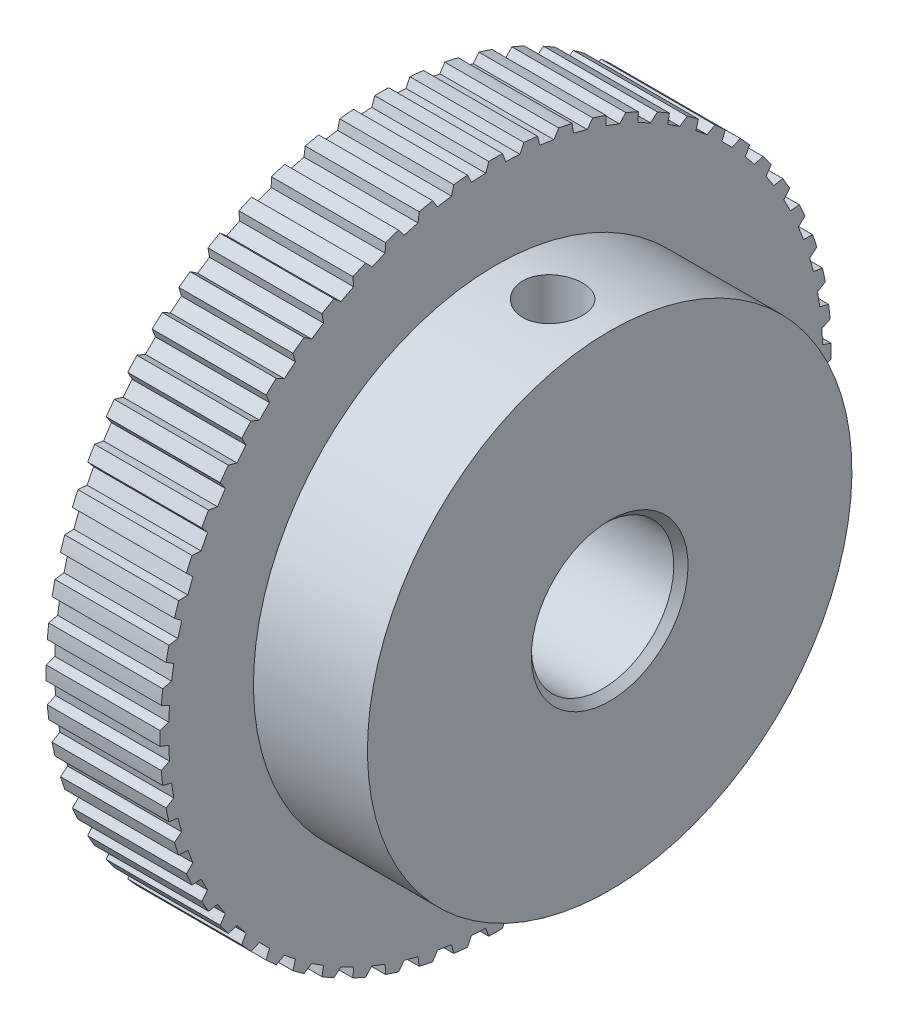
from build123d import *

# Parameters (mm, degrees)
ENL_V_MAT_EXTRU_2_DEPTH = 17
ESQUISSE3_R             = 5
ENL_V_MAT_EXTRU_3_DEPTH = 17
CHANFREIN1_SIZE         = 0.5
ESQUISSE4_W             = 2.1
ESQUISSE4_H             = 23.55


with BuildPart() as part:
    # Esquisse1 → Révolution1 (revolve)
    with BuildSketch(Plane.XY):
        Polygon((0, 0), (0, 21.05), (0, 23.55), (8, 23.55), (8, 21.05), (8, 17), (16, 17), (16, 0), align=None)
    revolve(axis=Axis((16, 0, 0), (-1, 0, 0)))

    # Esquisse2 → Enlèv. mat.-Extru.2 (cut, through all)
    with BuildSketch(Plane.ZY):
        Polygon((0.701110196, 22.944751712), (0.418973605, 23.719915625), (2.062727906, 23.633770113), (1.701110196, 22.892343933), align=None)
        Polygon((3.095649077, 22.74577199), (2.896084753, 23.546180779), (4.521829737, 23.288688069), (4.084692868, 22.589122843), align=None)
        Polygon((5.45627138, 22.297584831), (5.34146579, 23.114469048), (6.931389456, 22.688450285), (6.42352279, 22.038410596), align=None)
        Polygon((7.757113631, 21.605100665), (7.72832461, 22.429510357), (9.265007422, 21.839633093), (8.691975253, 21.246240911), align=None)
        Polygon((9.972967322, 20.675906496), (10.030510289, 21.498809258), (11.497116027, 20.751536309), (10.865196616, 20.221292964), align=None)
        Polygon((12.079555097, 19.520182768), (12.222799598, 20.332562705), (13.603259824, 19.436081352), (12.919376611, 18.9747963), align=None)
        Polygon((14.053796737, 18.150591834), (14.281173357, 18.94354834), (15.560363459, 17.90768062), (14.832009212, 17.520407797), align=None)
        Polygon((15.87406204, 16.582139216), (16.183079591, 17.346984495), (17.346984495, 16.183079591), (16.582139216, 15.87406204), align=None)
        Polygon((17.520407797, 14.832009212), (17.90768062, 15.560363459), (18.94354834, 14.281173357), (18.150591834, 14.053796737), align=None)
        Polygon((18.9747963, 12.919376611), (19.436081352, 13.603259824), (20.332562705, 12.222799598), (19.520182768, 12.079555097), align=None)
        Polygon((20.221292964, 10.865196616), (20.751536309, 11.497116027), (21.498809258, 10.030510289), (20.675906496, 9.972967322), align=None)
        Polygon((21.246240911, 8.691975253), (21.839633093, 9.265007422), (22.429510357, 7.72832461), (21.605100665, 7.757113631), align=None)
        Polygon((22.038410596, 6.42352279), (22.688450285, 6.931389456), (23.114469048, 5.34146579), (22.297584831, 5.45627138), align=None)
        Polygon((22.589122843, 4.084692868), (23.288688069, 4.521829737), (23.546180779, 2.896084753), (22.74577199, 3.095649077), align=None)
        Polygon((22.892343933, 1.701110196), (23.633770113, 2.062727906), (23.719915625, 0.418973605), (22.944751712, 0.701110196), align=None)
        Polygon((22.944751712, -0.701110196), (23.719915625, -0.418973605), (23.633770113, -2.062727906), (22.892343933, -1.701110196), align=None)
        Polygon((22.74577199, -3.095649077), (23.546180779, -2.896084753), (23.288688069, -4.521829737), (22.589122843, -4.084692868), align=None)
        Polygon((22.297584831, -5.45627138), (23.114469048, -5.34146579), (22.688450285, -6.931389456), (22.038410596, -6.42352279), align=None)
        Polygon((21.605100665, -7.757113631), (22.429510357, -7.72832461), (21.839633093, -9.265007422), (21.246240911, -8.691975253), align=None)
        Polygon((20.675906496, -9.972967322), (21.498809258, -10.030510289), (20.751536309, -11.497116027), (20.221292964, -10.865196616), align=None)
        Polygon((19.520182768, -12.079555097), (20.332562705, -12.222799598), (19.436081352, -13.603259824), (18.9747963, -12.919376611), align=None)
        Polygon((18.150591834, -14.053796737), (18.94354834, -14.281173357), (17.90768062, -15.560363459), (17.520407797, -14.832009212), align=None)
        Polygon((16.582139216, -15.87406204), (17.346984495, -16.183079591), (16.183079591, -17.346984495), (15.87406204, -16.582139216), align=None)
        Polygon((14.832009212, -17.520407797), (15.560363459, -17.90768062), (14.281173357, -18.94354834), (14.053796737, -18.150591834), align=None)
        Polygon((12.919376611, -18.9747963), (13.603259824, -19.436081352), (12.222799598, -20.332562705), (12.079555097, -19.520182768), align=None)
        Polygon((10.865196616, -20.221292964), (11.497116027, -20.751536309), (10.030510289, -21.498809258), (9.972967322, -20.675906496), align=None)
        Polygon((8.691975253, -21.246240911), (9.265007422, -21.839633093), (7.72832461, -22.429510357), (7.757113631, -21.605100665), align=None)
        Polygon((6.42352279, -22.038410596), (6.931389456, -22.688450285), (5.34146579, -23.114469048), (5.45627138, -22.297584831), align=None)
        Polygon((4.084692868, -22.589122843), (4.521829737, -23.288688069), (2.896084753, -23.546180779), (3.095649077, -22.74577199), align=None)
        Polygon((1.701110196, -22.892343933), (2.062727906, -23.633770113), (0.418973605, -23.719915625), (0.701110196, -22.944751712), align=None)
        Polygon((-0.701110196, -22.944751712), (-0.418973605, -23.719915625), (-2.062727906, -23.633770113), (-1.701110196, -22.892343933), align=None)
        Polygon((-3.095649077, -22.74577199), (-2.896084753, -23.546180779), (-4.521829737, -23.288688069), (-4.084692868, -22.589122843), align=None)
        Polygon((-5.45627138, -22.297584831), (-5.34146579, -23.114469048), (-6.931389456, -22.688450285), (-6.42352279, -22.038410596), align=None)
        Polygon((-7.757113631, -21.605100665), (-7.72832461, -22.429510357), (-9.265007422, -21.839633093), (-8.691975253, -21.246240911), align=None)
        Polygon((-9.972967322, -20.675906496), (-10.030510289, -21.498809258), (-11.497116027, -20.751536309), (-10.865196616, -20.221292964), align=None)
        Polygon((-12.079555097, -19.520182768), (-12.222799598, -20.332562705), (-13.603259824, -19.436081352), (-12.919376611, -18.9747963), align=None)
        Polygon((-14.053796737, -18.150591834), (-14.281173357, -18.94354834), (-15.560363459, -17.90768062), (-14.832009212, -17.520407797), align=None)
        Polygon((-15.87406204, -16.582139216), (-16.183079591, -17.346984495), (-17.346984495, -16.183079591), (-16.582139216, -15.87406204), align=None)
        Polygon((-17.520407797, -14.832009212), (-17.90768062, -15.560363459), (-18.94354834, -14.281173357), (-18.150591834, -14.053796737), align=None)
        Polygon((-18.9747963, -12.919376611), (-19.436081352, -13.603259824), (-20.332562705, -12.222799598), (-19.520182768, -12.079555097), align=None)
        Polygon((-20.221292964, -10.865196616), (-20.751536309, -11.497116027), (-21.498809258, -10.030510289), (-20.675906496, -9.972967322), align=None)
        Polygon((-21.246240911, -8.691975253), (-21.839633093, -9.265007422), (-22.429510357, -7.72832461), (-21.605100665, -7.757113631), align=None)
        Polygon((-22.038410596, -6.42352279), (-22.688450285, -6.931389456), (-23.114469048, -5.34146579), (-22.297584831, -5.45627138), align=None)
        Polygon((-22.589122843, -4.084692868), (-23.288688069, -4.521829737), (-23.546180779, -2.896084753), (-22.74577199, -3.095649077), align=None)
        Polygon((-22.892343933, -1.701110196), (-23.633770113, -2.062727906), (-23.719915625, -0.418973605), (-22.944751712, -0.701110196), align=None)
        Polygon((-22.944751712, 0.701110196), (-23.719915625, 0.418973605), (-23.633770113, 2.062727906), (-22.892343933, 1.701110196), align=None)
        Polygon((-22.74577199, 3.095649077), (-23.546180779, 2.896084753), (-23.288688069, 4.521829737), (-22.589122843, 4.084692868), align=None)
        Polygon((-22.297584831, 5.45627138), (-23.114469048, 5.34146579), (-22.688450285, 6.931389456), (-22.038410596, 6.42352279), align=None)
        Polygon((-21.605100665, 7.757113631), (-22.429510357, 7.72832461), (-21.839633093, 9.265007422), (-21.246240911, 8.691975253), align=None)
        Polygon((-20.675906496, 9.972967322), (-21.498809258, 10.030510289), (-20.751536309, 11.497116027), (-20.221292964, 10.865196616), align=None)
        Polygon((-19.520182768, 12.079555097), (-20.332562705, 12.222799598), (-19.436081352, 13.603259824), (-18.9747963, 12.919376611), align=None)
        Polygon((-18.150591834, 14.053796737), (-18.94354834, 14.281173357), (-17.90768062, 15.560363459), (-17.520407797, 14.832009212), align=None)
        Polygon((-16.582139216, 15.87406204), (-17.346984495, 16.183079591), (-16.183079591, 17.346984495), (-15.87406204, 16.582139216), align=None)
        Polygon((-14.832009212, 17.520407797), (-15.560363459, 17.90768062), (-14.281173357, 18.94354834), (-14.053796737, 18.150591834), align=None)
        Polygon((-12.919376611, 18.9747963), (-13.603259824, 19.436081352), (-12.222799598, 20.332562705), (-12.079555097, 19.520182768), align=None)
        Polygon((-10.865196616, 20.221292964), (-11.497116027, 20.751536309), (-10.030510289, 21.498809258), (-9.972967322, 20.675906496), align=None)
        Polygon((-8.691975253, 21.246240911), (-9.265007422, 21.839633093), (-7.72832461, 22.429510357), (-7.757113631, 21.605100665), align=None)
        Polygon((-6.42352279, 22.038410596), (-6.931389456, 22.688450285), (-5.34146579, 23.114469048), (-5.45627138, 22.297584831), align=None)
        Polygon((-4.084692868, 22.589122843), (-4.521829737, 23.288688069), (-2.896084753, 23.546180779), (-3.095649077, 22.74577199), align=None)
        Polygon((-1.701110196, 22.892343933), (-2.062727906, 23.633770113), (-0.418973605, 23.719915625), (-0.701110196, 22.944751712), align=None)
    extrude(amount=-ENL_V_MAT_EXTRU_2_DEPTH, mode=Mode.SUBTRACT)

    # Esquisse3 → Enlèv. mat.-Extru.3 (cut, through all)
    with BuildSketch(Plane(origin=(16, 0, 0), x_dir=(0, 0, -1), z_dir=(1, 0, 0))):
        with Locations(Location((0, 0, 0), (0, 0, 90))):  # turned: the seam where the file's is
            Circle(ESQUISSE3_R)
    extrude(amount=-ENL_V_MAT_EXTRU_3_DEPTH, mode=Mode.SUBTRACT)

    # Chanfrein1
    chanfrein1_edges = [part.edges().sort_by_distance(p)[0] for p in [
        (0, -5, 0),
        (16, -5, 0),
    ]]
    chamfer(chanfrein1_edges, length=CHANFREIN1_SIZE)

    # Esquisse4 → Trou taraudé M51 (revolve, cut)
    with BuildSketch(Plane(origin=(12, 0, 0), x_dir=(0, 0, -1), z_dir=(1, 0, 0))):
        with Locations((1.05, 11.775)):
            Rectangle(ESQUISSE4_W, ESQUISSE4_H)
    revolve(axis=Axis((12, -6.35, 0), (0, 1, 0)), mode=Mode.SUBTRACT)


solid = part.part
